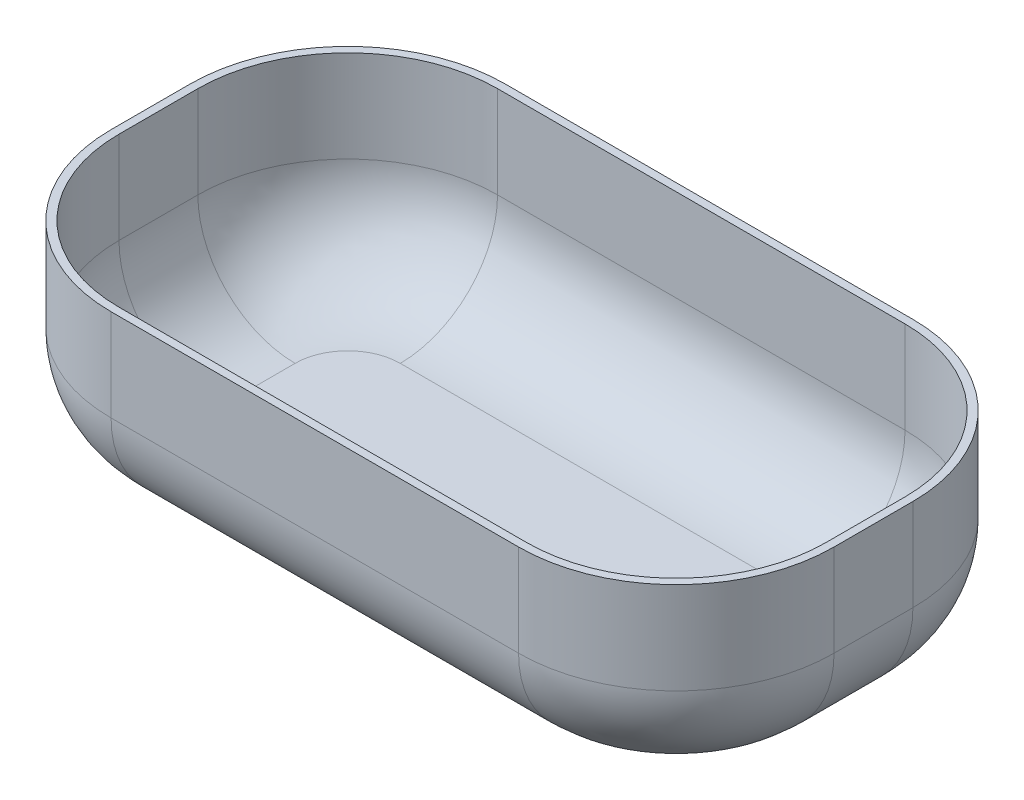
from build123d import *

# Parameters (mm, degrees)
CROQUIS1_W              = 550
CROQUIS1_H              = 150
SALIENTE_EXTRUIR1_DEPTH = 150
REDONDEO1_R             = 120
REDONDEO2_R             = 80
VACIADO1_T              = -6


with BuildPart() as part:
    # Croquis1 → Saliente-Extruir1 (new body, symmetric)
    with BuildSketch(Plane.XY):
        with Locations((0, -75)):
            Rectangle(CROQUIS1_W, CROQUIS1_H)
    extrude(amount=SALIENTE_EXTRUIR1_DEPTH, both=True)

    # Redondeo1
    redondeo1_edges = [part.edges().sort_by_distance(p)[0] for p in [
        (275, -75, 150),
        (-275, -75, 150),
        (275, -75, -150),
        (-275, -75, -150),
    ]]
    fillet(redondeo1_edges, radius=REDONDEO1_R)

    # Redondeo2
    redondeo2_edges = [part.edges().sort_by_distance(p)[0] for p in [
        (275, -150, 0),
        (0, -150, -150),
        (0, -150, 150),
        (-275, -150, 0),
        (-239.852813742, -150, 114.852813742),
        (-239.852813742, -150, -114.852813742),
        (239.852813742, -150, 114.852813742),
        (239.852813742, -150, -114.852813742),
    ]]
    fillet(redondeo2_edges, radius=REDONDEO2_R)

    # Vaciado1
    vaciado1_openings = [part.faces().sort_by_distance(p)[0] for p in [
        (0, 0, 0),
    ]]
    offset(amount=VACIADO1_T, openings=vaciado1_openings, kind=Kind.INTERSECTION)


solid = part.part
